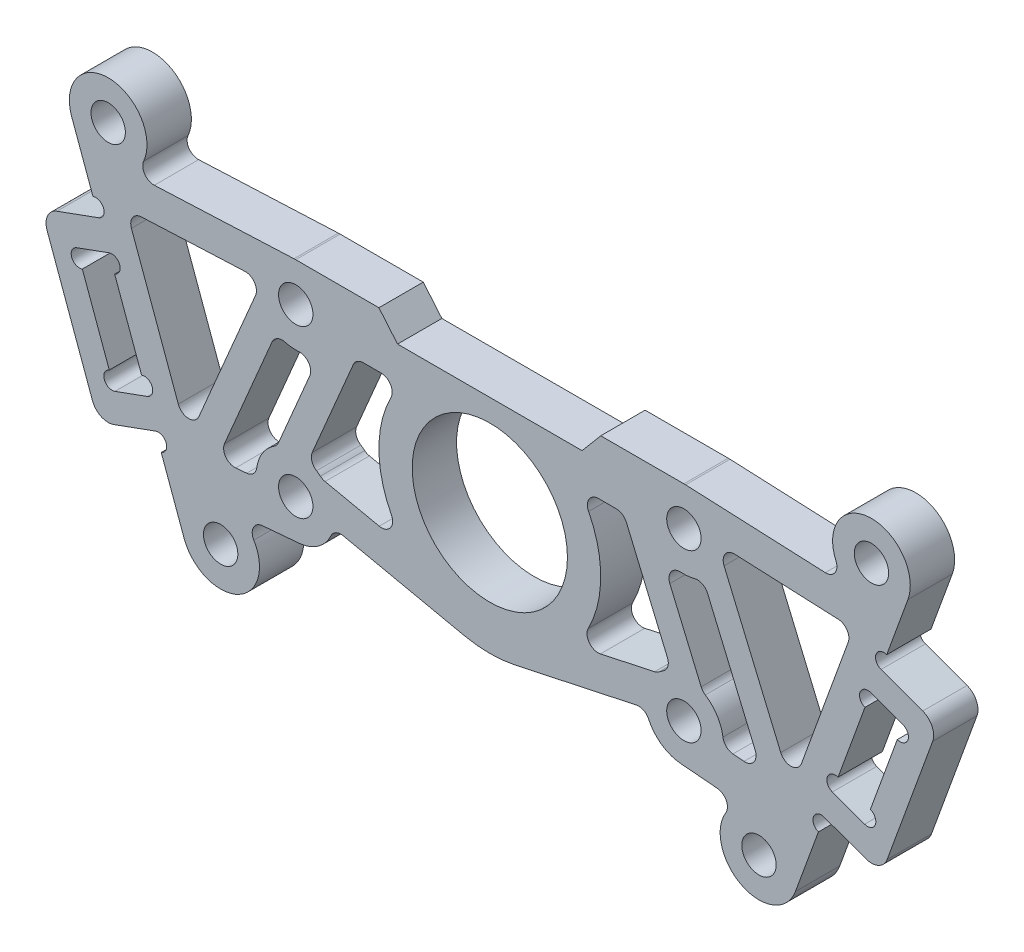
from build123d import *

# Parameters (mm, degrees)
SKETCH_1_R             = 7
SKETCH_1_R_2           = 1.55
EXTRUDE_1_DEPTH        = 2
FILLET_1_R             = 1
CUT_EXTRUDE_START      = -5
CUT_EXTRUDE_1_DEPTH    = 6
FILLET_2_R             = 1
FILLET_2_OF_MIRROR_1_R = 1
SKETCH_3_R             = 1.55
EXTRUDE_2_DEPTH        = 4
FILLET_3_R             = 1
CUT_EXTRUDE_2_DEPTH    = 5
FILLET_4_R             = 1
CUT_EXTRUDE_3_DEPTH    = 5
EXTRUDE_3_DEPTH        = 4
SKETCH_8_R             = 0.75
CUT_EXTRUDE_4_DEPTH    = 5
FILLET_5_R             = 1.5


with BuildPart() as part:
    # 草图1 → 凸台-拉伸1 (new body, symmetric)
    with BuildSketch(Plane.XY):
        with BuildLine():
            Line((-17.5, 11), (-10, 11))
            Line((-10, 11), (-8.321800738, 9))
            Line((-8.321800738, 9), (8.321800738, 9))
            Line((8.321800738, 9), (10, 11))
            Line((10, 11), (17.5, 11))
            ThreePointArc((17.5, 11), (17.577641076, 10.999138732), (17.655243941, 10.99655535))
            Line((17.655243941, 10.99655535), (37, 10.137665421))
            Line((37, 10.137665421), (28.942548731, -12))
            Line((28.942548731, -12), (17.199216279, -10.987051642))
            ThreePointArc((17.199216279, -10.987051642), (15.184578245, -10.124656567), (14.077678472, -8.233290774))
            Line((14.077678472, -8.233290774), (2.304628146, -10.75586766))
            ThreePointArc((2.304628146, -10.75586766), (0, -11), (-2.304628146, -10.75586766))
            Line((-2.304628146, -10.75586766), (-14.077678472, -8.233290774))
            ThreePointArc((-14.077678472, -8.233290774), (-15.184578245, -10.124656567), (-17.199216279, -10.987051642))
            Line((-17.199216279, -10.987051642), (-28.942548731, -12))
            Line((-28.942548731, -12), (-37, 10.137665421))
            Line((-37, 10.137665421), (-17.655243941, 10.99655535))
            ThreePointArc((-17.655243941, 10.99655535), (-17.577641076, 10.999138732), (-17.5, 11))
        make_face()
        Circle(SKETCH_1_R, mode=Mode.SUBTRACT)
        with Locations((17.5, 7.5)):
            Circle(SKETCH_1_R_2, mode=Mode.SUBTRACT)
        with Locations((17.5, -7.5)):
            Circle(SKETCH_1_R_2, mode=Mode.SUBTRACT)
        with Locations((-17.5, -7.5)):
            Circle(SKETCH_1_R_2, mode=Mode.SUBTRACT)
        with Locations((-17.5, 7.5)):
            Circle(SKETCH_1_R_2, mode=Mode.SUBTRACT)
    extrude(amount=EXTRUDE_1_DEPTH, both=True)

    # 圆角1
    fillet_1_edges = [part.edges().sort_by_distance(p)[0] for p in [
        (14.077678472, -8.233290774, 0),
        (-14.077678472, -8.233290774, 0),
    ]]
    fillet(fillet_1_edges, radius=FILLET_1_R)

    # 草图2 → 切除-拉伸1 (cut)
    with BuildSketch(Plane.XY.offset(2).offset(CUT_EXTRUDE_START)):
        Polygon((-20.5, 7.867295251), (-32.782632739, 7.321957304), (-27.222903771, -7.953272497), align=None)
        with BuildLine():
            Line((-19.251811465, 4.412338006), (-24.573190843, -8.11011447))
            Line((-24.573190843, -8.11011447), (-21.036866665, -7.805080632))
            ThreePointArc((-21.036866665, -7.805080632), (-20.623106229, -5.812188553), (-19.182687898, -4.374130291))
            Line((-19.182687898, -4.374130291), (-15.331076504, 4.689613751))
            ThreePointArc((-15.331076504, 4.689613751), (-17.24956823, 3.958844267), (-19.251811465, 4.412338006))
        make_face()
    cut_extrude_1 = extrude(amount=CUT_EXTRUDE_1_DEPTH, mode=Mode.SUBTRACT)

    # 圆角2
    fillet_2_edges = [part.edges().sort_by_distance(p)[0] for p in [
        (-20.5, 7.867295251, 0),
        (-27.222903771, -7.953272497, 0),
        (-32.782632739, 7.321957304, 0),
        (-19.251811465, 4.412338006, 0),
        (-15.331076504, 4.689613751, 0),
        (-19.182687898, -4.374130291, 0),
        (-21.036866665, -7.805080632, 0),
        (-24.573190843, -8.11011447, 0),
    ]]
    fillet(fillet_2_edges, radius=FILLET_2_R)

    # 镜向1: 切除-拉伸1 across plane
    add(cut_extrude_1.mirror(Plane(origin=(0, 0, 0), x_dir=(0, 0, 1), z_dir=(1, 0, 0))), mode=Mode.SUBTRACT)

    # 圆角2 of 镜向1
    fillet_2_of_mirror_1_edges = [part.edges().sort_by_distance(p)[0] for p in [
        (20.5, 7.867295251, 0),
        (27.222903771, -7.953272497, 0),
        (32.782632739, 7.321957304, 0),
        (19.251811465, 4.412338006, 0),
        (15.331076504, 4.689613751, 0),
        (19.182687898, -4.374130291, 0),
        (21.036866665, -7.805080632, 0),
        (24.573190843, -8.11011447, 0),
    ]]
    fillet(fillet_2_of_mirror_1_edges, radius=FILLET_2_OF_MIRROR_1_R)

    # 草图3 → 凸台-拉伸2 (add)
    with BuildSketch(Plane.XY.offset(2)):
        with BuildLine():
            Line((-37.69913918, 12.058534531), (-37, 10.137665421))
            Line((-37, 10.137665421), (-32.4761474, 10.338520445))
            ThreePointArc((-32.4761474, 10.338520445), (-33.315445081, 16.579981486), (-37.69913918, 12.058534531))
        make_face()
        with Locations((-34.410215007, 13.255605032)):
            Circle(SKETCH_3_R, mode=Mode.SUBTRACT)
        with BuildLine():
            Line((-27.557621455, -15.805056417), (-28.942548731, -12))
            Line((-28.942548731, -12), (-22.730405687, -11.464157204))
            ThreePointArc((-22.730405687, -11.464157204), (-21.928391725, -17.210478932), (-27.557621455, -15.805056417))
        make_face()
        with Locations((-24.268697282, -14.607985915)):
            Circle(SKETCH_3_R, mode=Mode.SUBTRACT)
    extrude_2 = extrude(amount=-EXTRUDE_2_DEPTH)

    # 镜向2: 凸台-拉伸2 across plane
    add(extrude_2.mirror(Plane(origin=(0, 0, 0), x_dir=(0, 0, 1), z_dir=(1, 0, 0))))

    # 圆角3
    fillet_3_edges = [part.edges().sort_by_distance(p)[0] for p in [
        (-22.730405687, -11.464157204, 0),
        (-32.4761474, 10.338520445, 0),
        (22.730405687, -11.464157204, 0),
        (32.4761474, 10.338520445, 0),
    ]]
    fillet(fillet_3_edges, radius=FILLET_3_R)

    # 草图4 → 切除-拉伸2 (cut, through all)
    with BuildSketch(Plane.XY.offset(2)):
        with BuildLine():
            Line((-16.384851826, -4.1824038), (-12.057869255, 6))
            Line((-12.057869255, 6), (-8, 6))
            ThreePointArc((-8, 6), (-9.993390733, -0.363512948), (-7.542930102, -6.565379309))
            Line((-7.542930102, -6.565379309), (-15.108699944, -4.944284045))
            ThreePointArc((-15.108699944, -4.944284045), (-15.705867849, -4.49482283), (-16.384851826, -4.1824038))
        make_face()
    cut_extrude_2 = extrude(amount=-CUT_EXTRUDE_2_DEPTH, mode=Mode.SUBTRACT)

    # 镜向3: 切除-拉伸2 across plane
    add(cut_extrude_2.mirror(Plane(origin=(0, 0, 0), x_dir=(0, 0, 1), z_dir=(1, 0, 0))), mode=Mode.SUBTRACT)

    # 圆角4
    fillet_4_edges = [part.edges().sort_by_distance(p)[0] for p in [
        (-12.057869255, 6, 0),
        (-8, 6, 0),
        (-7.542930102, -6.565379309, 0),
        (-15.108699944, -4.944284045, 0),
        (-16.384851826, -4.1824038, 0),
        (8, 6, 0),
        (12.057869255, 6, 0),
        (16.384851826, -4.1824038, 0),
        (15.108699944, -4.944284045, 0),
        (7.542930102, -6.565379309, 0),
    ]]
    fillet(fillet_4_edges, radius=FILLET_4_R)

    # 草图5 → 切除-拉伸3 (cut, through all)
    with BuildSketch(Plane.XY.offset(2)):
        Polygon((30.884976598, -6.370842854), (33.798023723, -7.431105298), (37.25242717, 2.059790172), (34.339380046, 3.120052616), align=None)
    cut_extrude_3 = extrude(amount=-CUT_EXTRUDE_3_DEPTH, mode=Mode.SUBTRACT)

    # 草图7 → 凸台-拉伸3 (add)
    with BuildSketch(Plane.XY.offset(2)):
        Polygon((35.271298659, 5.388097522), (40.439608074, 3.506986734), (35.309305924, -10.588402578), (30.140996509, -8.707291789), (30.97894586, -6.405044868), (33.798023723, -7.431105298), (37.25242717, 2.059790172), (34.433349308, 3.085850601), align=None)
    extrude_3 = extrude(amount=-EXTRUDE_3_DEPTH)

    # 镜向4: 切除-拉伸3, 凸台-拉伸3 across plane
    add(cut_extrude_3.mirror(Plane(origin=(0, 0, 0), x_dir=(0, 0, 1), z_dir=(1, 0, 0))), mode=Mode.SUBTRACT)
    add(extrude_3.mirror(Plane(origin=(0, 0, 0), x_dir=(0, 0, 1), z_dir=(1, 0, 0))))

    # 草图8 → 切除-拉伸4 (cut, through all)
    with BuildSketch(Plane(origin=(0, 0, -2), x_dir=(-1, 0, 0), z_dir=(0, 0, -1))):
        with Locations((-36.995912063, 1.355020706)):
            Circle(SKETCH_8_R)
        with Locations((-34.082864939, 2.41528315)):
            Circle(SKETCH_8_R)
        with Locations((-34.05453883, -6.726335833)):
            Circle(SKETCH_8_R)
        with Locations((-31.141491706, -5.666073389)):
            Circle(SKETCH_8_R)
        with Locations((-35.527813767, 6.092866988)):
            Circle(SKETCH_8_R)
        with Locations((-29.884481402, -9.412061255)):
            Circle(SKETCH_8_R)
    cut_extrude_4 = extrude(amount=-CUT_EXTRUDE_4_DEPTH, mode=Mode.SUBTRACT)

    # 镜向5: 切除-拉伸4 across plane
    add(cut_extrude_4.mirror(Plane(origin=(0, 0, 0), x_dir=(0, 0, 1), z_dir=(1, 0, 0))), mode=Mode.SUBTRACT)

    # 圆角5
    fillet_5_edges = [part.edges().sort_by_distance(p)[0] for p in [
        (40.439608074, 3.506986734, 0),
        (35.309305924, -10.588402578, 0),
        (-40.439608074, 3.506986734, 0),
        (-35.309305924, -10.588402578, 0),
    ]]
    fillet(fillet_5_edges, radius=FILLET_5_R)


solid = part.part
